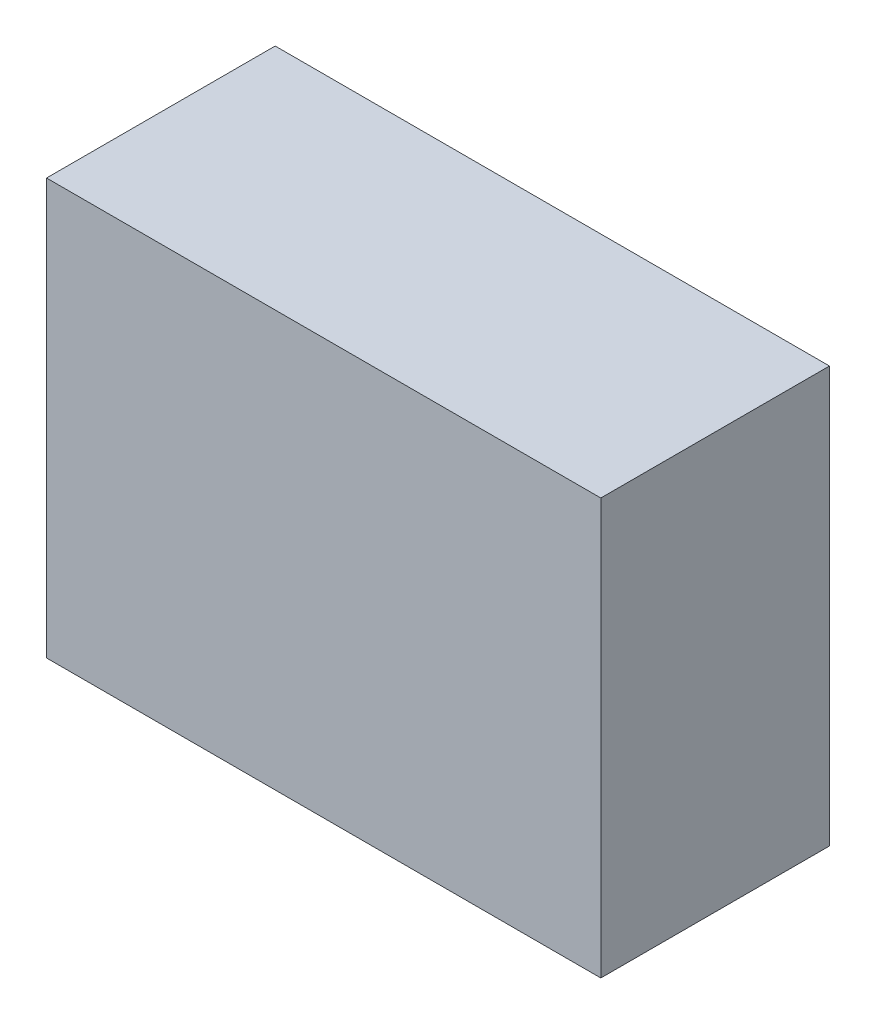
from build123d import *

# Parameters (mm, degrees)
SKETCH1_W           = 400
SKETCH1_H           = 300
BOSS_EXTRUDE1_DEPTH = 165


with BuildPart() as part:
    # Sketch1 → Boss-Extrude1 (new body)
    with BuildSketch(Plane.XY):
        with Locations((-23.516483516, -3.846153846)):
            Rectangle(SKETCH1_W, SKETCH1_H)
    extrude(amount=BOSS_EXTRUDE1_DEPTH)


solid = part.part
